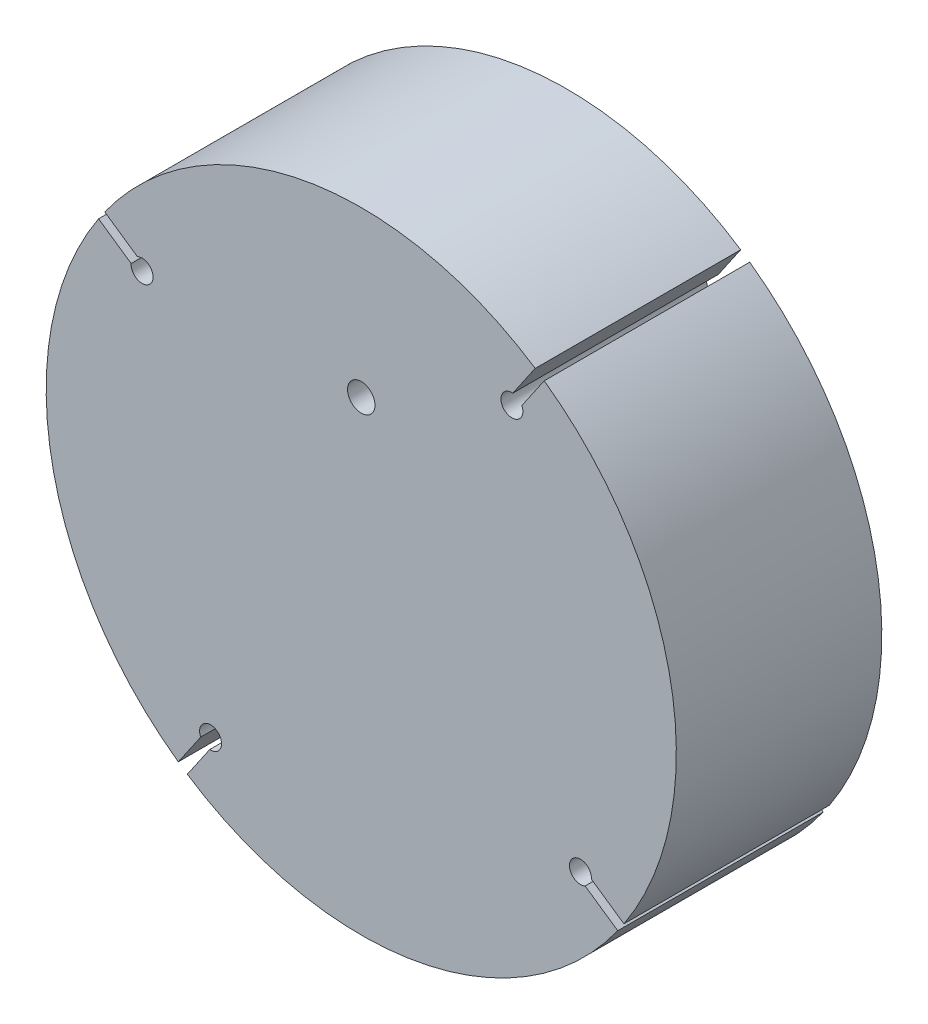
from build123d import *

# Parameters (mm, degrees)
SCHIZZO1_R                   = 115
ESTRUSIONE_ESTRUSIONE1_DEPTH = 75
TAGLIO_ESTRUSIONE1_REACH     = 77
SCHIZZO3_W                   = 60
SCHIZZO3_H                   = 60
TAGLIO_ESTRUSIONE2_DEPTH     = 15
SCHIZZO4_W                   = 50
SCHIZZO4_H                   = 70
TAGLIO_ESTRUSIONE3_DEPTH     = 25
SCHIZZO5_R                   = 5
TAGLIO_ESTRUSIONE4_DEPTH     = 76
SCHIZZO6_W                   = 45
SCHIZZO6_H                   = 45
TAGLIO_ESTRUSIONE5_DEPTH     = 12


with BuildPart() as part:
    # Schizzo1 → Estrusione-Estrusione1 (new body)
    with BuildSketch(Plane.XY):
        Circle(SCHIZZO1_R)
    extrude(amount=ESTRUSIONE_ESTRUSIONE1_DEPTH)

    # Schizzo2 → Taglio-Estrusione1 (cut, up to next)
    with BuildSketch(Plane(origin=(0, 0, 0), x_dir=(-1, 0, 0), z_dir=(0, 0, -1)), mode=Mode.PRIVATE) as taglio_estrusione1_sk1:
        with BuildLine():
            Line((58.610597259, -81.721507315), (66.78904506, -93.617431389))
            ThreePointArc((66.78904506, -93.617431389), (65.150814632, -94.764821283), (63.492877363, -95.883546681))
            Line((63.492877363, -95.883546681), (55.314429562, -83.987622606))
            ThreePointArc((55.314429562, -83.987622606), (52.733884708, -76.703832303), (58.610597259, -81.721507315))
        make_face()
    taglio_estrusione1_tool1 = extrude(taglio_estrusione1_sk1.sketch, amount=-TAGLIO_ESTRUSIONE1_REACH, mode=Mode.PRIVATE) & part.part
    add(taglio_estrusione1_tool1.solids().sort_by_distance((-58.254036, -84.733143, 0))[0], mode=Mode.SUBTRACT)
    # Schizzo2 → Taglio-Estrusione1 (cut, up to next)
    with BuildSketch(Plane(origin=(0, 0, 0), x_dir=(-1, 0, 0), z_dir=(0, 0, -1)), mode=Mode.PRIVATE) as taglio_estrusione1_sk2:
        with BuildLine():
            Line((81.721507315, 58.610597259), (93.617431389, 66.78904506))
            ThreePointArc((93.617431389, 66.78904506), (94.764821283, 65.150814632), (95.883546681, 63.492877363))
            Line((95.883546681, 63.492877363), (83.987622606, 55.314429562))
            ThreePointArc((83.987622606, 55.314429562), (76.703832303, 52.733884708), (81.721507315, 58.610597259))
        make_face()
    taglio_estrusione1_tool2 = extrude(taglio_estrusione1_sk2.sketch, amount=-TAGLIO_ESTRUSIONE1_REACH, mode=Mode.PRIVATE) & part.part
    add(taglio_estrusione1_tool2.solids().sort_by_distance((-84.733143, 58.254036, 0))[0], mode=Mode.SUBTRACT)
    # Schizzo2 → Taglio-Estrusione1 (cut, up to next)
    with BuildSketch(Plane(origin=(0, 0, 0), x_dir=(-1, 0, 0), z_dir=(0, 0, -1)), mode=Mode.PRIVATE) as taglio_estrusione1_sk3:
        with BuildLine():
            Line((-58.610597259, 81.721507315), (-66.78904506, 93.617431389))
            ThreePointArc((-66.78904506, 93.617431389), (-65.150814632, 94.764821283), (-63.492877363, 95.883546681))
            Line((-63.492877363, 95.883546681), (-55.314429562, 83.987622606))
            ThreePointArc((-55.314429562, 83.987622606), (-52.733884708, 76.703832303), (-58.610597259, 81.721507315))
        make_face()
    taglio_estrusione1_tool3 = extrude(taglio_estrusione1_sk3.sketch, amount=-TAGLIO_ESTRUSIONE1_REACH, mode=Mode.PRIVATE) & part.part
    add(taglio_estrusione1_tool3.solids().sort_by_distance((58.254036, 84.733143, 0))[0], mode=Mode.SUBTRACT)
    # Schizzo2 → Taglio-Estrusione1 (cut, up to next)
    with BuildSketch(Plane(origin=(0, 0, 0), x_dir=(-1, 0, 0), z_dir=(0, 0, -1)), mode=Mode.PRIVATE) as taglio_estrusione1_sk4:
        with BuildLine():
            Line((-81.721507315, -58.610597259), (-93.617431389, -66.78904506))
            ThreePointArc((-93.617431389, -66.78904506), (-94.764821283, -65.150814632), (-95.883546681, -63.492877363))
            Line((-95.883546681, -63.492877363), (-83.987622606, -55.314429562))
            ThreePointArc((-83.987622606, -55.314429562), (-76.703832303, -52.733884708), (-81.721507315, -58.610597259))
        make_face()
    taglio_estrusione1_tool4 = extrude(taglio_estrusione1_sk4.sketch, amount=-TAGLIO_ESTRUSIONE1_REACH, mode=Mode.PRIVATE) & part.part
    add(taglio_estrusione1_tool4.solids().sort_by_distance((84.733143, -58.254036, 0))[0], mode=Mode.SUBTRACT)

    # Schizzo3 → Taglio-Estrusione2 (cut)
    with BuildSketch(Plane(origin=(0, 0, 0), x_dir=(-1, 0, 0), z_dir=(0, 0, -1))):
        with Locations((-35, 0)):
            Rectangle(SCHIZZO3_W, SCHIZZO3_H)
    extrude(amount=-TAGLIO_ESTRUSIONE2_DEPTH, mode=Mode.SUBTRACT)

    # Schizzo4 → Taglio-Estrusione3 (cut)
    with BuildSketch(Plane(origin=(0, 0, 0), x_dir=(-1, 0, 0), z_dir=(0, 0, -1))):
        with Locations((40, 0)):
            Rectangle(SCHIZZO4_W, SCHIZZO4_H)
    extrude(amount=-TAGLIO_ESTRUSIONE3_DEPTH, mode=Mode.SUBTRACT)

    # Schizzo5 → Taglio-Estrusione4 (cut, through all)
    with BuildSketch(Plane(origin=(0, 0, 0), x_dir=(-1, 0, 0), z_dir=(0, 0, -1))):
        with Locations((0, 55)):
            Circle(SCHIZZO5_R)
    extrude(amount=-TAGLIO_ESTRUSIONE4_DEPTH, mode=Mode.SUBTRACT)

    # Schizzo6 → Taglio-Estrusione5 (cut)
    with BuildSketch(Plane(origin=(0, 0, 0), x_dir=(-1, 0, 0), z_dir=(0, 0, -1))):
        with Locations((0, 84.5)):
            Rectangle(SCHIZZO6_W, SCHIZZO6_H)
    extrude(amount=-TAGLIO_ESTRUSIONE5_DEPTH, mode=Mode.SUBTRACT)


solid = part.part
